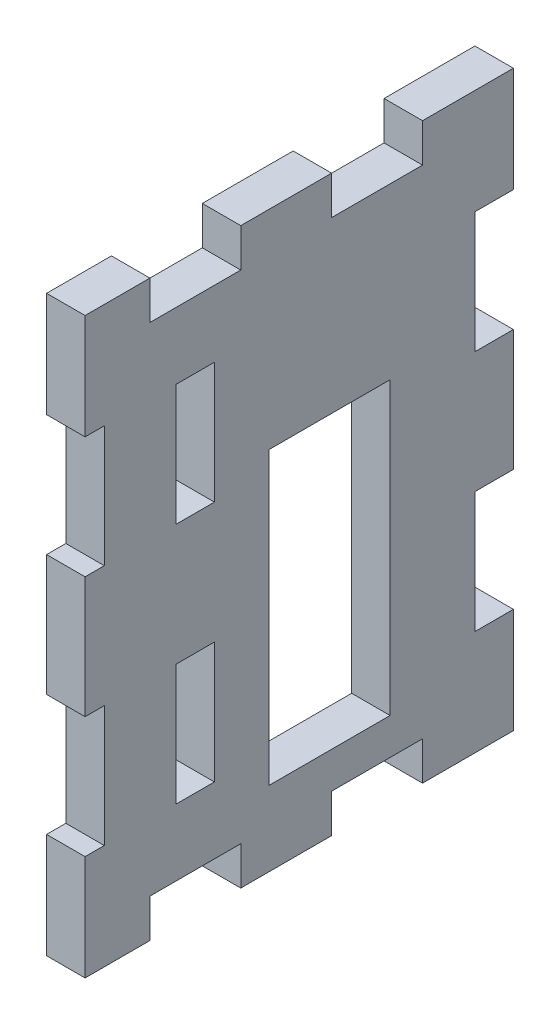
from build123d import *

# Parameters (mm, degrees)
SKETCH1_W           = 35.35
SKETCH1_H           = 47.35
SKETCH1_W_2         = 10
SKETCH1_H_2         = 24
BOSS_EXTRUDE1_DEPTH = 3.175
SKETCH2_W           = 3.175
SKETCH2_H           = 10
SKETCH2_W_2         = 1.5875
SKETCH2_W_3         = 7.5
SKETCH2_H_2         = 3.175
CUT_EXTRUDE1_DEPTH  = 4.175


with BuildPart() as part:
    # Sketch1 → Boss-Extrude1 (new body)
    with BuildSketch(Plane(origin=(0, 0, 0), x_dir=(0, 0, -1), z_dir=(1, 0, 0))):
        with Locations((17.675, 23.675)):
            Rectangle(SKETCH1_W, SKETCH1_H)
        with Locations((20.175, 18.175)):
            Rectangle(SKETCH1_W_2, SKETCH1_H_2, mode=Mode.SUBTRACT)
    extrude(amount=BOSS_EXTRUDE1_DEPTH)

    # Sketch2 → Cut-Extrude1 (cut, through all)
    with BuildSketch(Plane(origin=(3.175, 0, 0), x_dir=(0, 0, -1), z_dir=(1, 0, 0))):
        with Locations((33.7625, 33.675)):
            Rectangle(SKETCH2_W, SKETCH2_H)
        with Locations((33.7625, 13.675)):
            Rectangle(SKETCH2_W, SKETCH2_H)
        with Locations((9.0875, 13.675)):
            Rectangle(SKETCH2_W, SKETCH2_H)
        with Locations((9.0875, 33.675)):
            Rectangle(SKETCH2_W, SKETCH2_H)
        with Locations((0.79375, 33.675)):
            Rectangle(SKETCH2_W_2, SKETCH2_H)
        with Locations((0.79375, 13.675)):
            Rectangle(SKETCH2_W_2, SKETCH2_H)
        with Locations((24.1, 45.7625)):
            Rectangle(SKETCH2_W_3, SKETCH2_H_2)
        with Locations((9.1, 45.7625)):
            Rectangle(SKETCH2_W_3, SKETCH2_H_2)
        with Locations((9.1, 1.5875)):
            Rectangle(SKETCH2_W_3, SKETCH2_H_2)
        with Locations((24.1, 1.5875)):
            Rectangle(SKETCH2_W_3, SKETCH2_H_2)
    extrude(amount=-CUT_EXTRUDE1_DEPTH, mode=Mode.SUBTRACT)


solid = part.part
